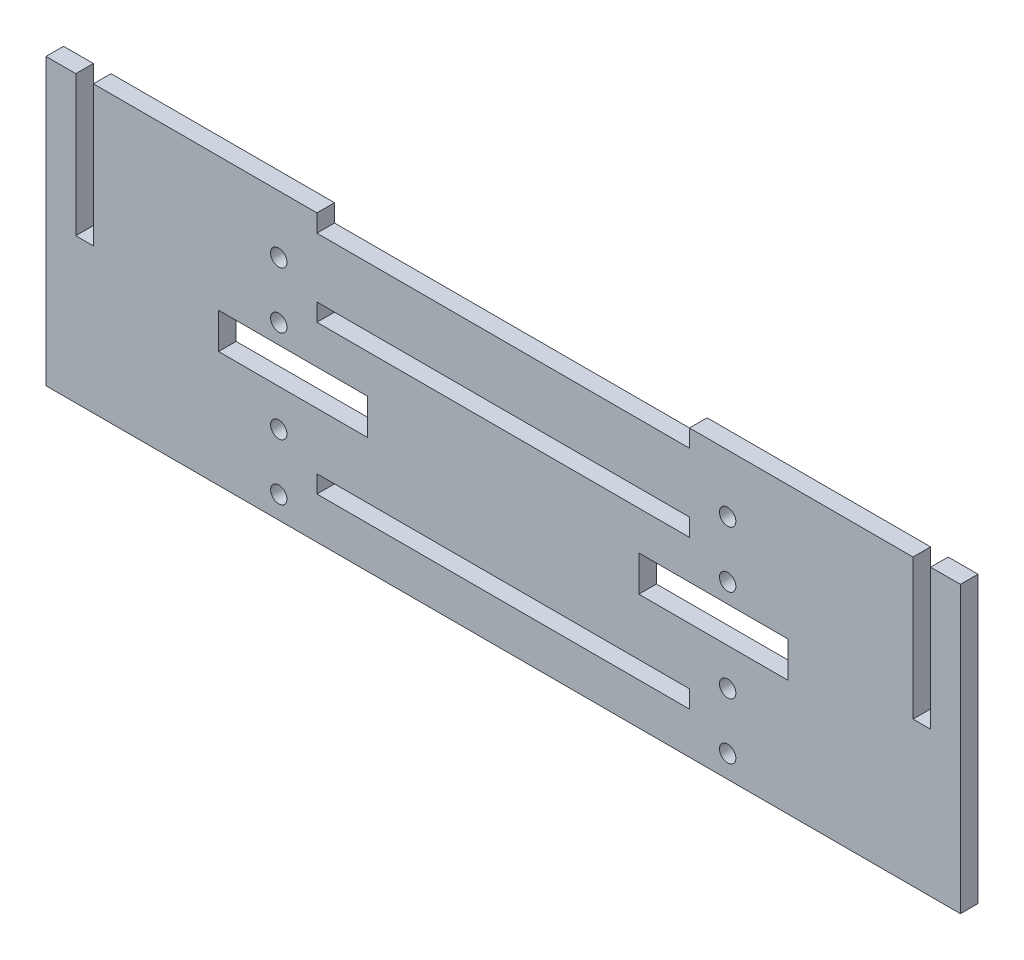
from build123d import *

# Parameters (mm, degrees)
SKETCH1_W           = 114.3
SKETCH1_H           = 2.9972
BOSS_EXTRUDE1_DEPTH = 2.9972
SKETCH2_R           = 1.397
CUT_EXTRUDE1_DEPTH  = 3.9972
SKETCH3_W           = 25.4
SKETCH3_H           = 2.9972
BOSS_EXTRUDE2_DEPTH = 2.9972
SKETCH4_W           = 155.8544
SKETCH4_H           = 0.762
BOSS_EXTRUDE3_DEPTH = 2.9972
SKETCH5_R           = 1.397
CUT_EXTRUDE2_DEPTH  = 3.9972
SKETCH7_R           = 1.397
CUT_EXTRUDE3_DEPTH  = 3.9972
SKETCH6_W           = 25.4
SKETCH6_H           = 6.096
CUT_EXTRUDE4_DEPTH  = 3.9972


with BuildPart() as part:
    # Sketch1 → Boss-Extrude1 (new body)
    with BuildSketch(Plane.XY):
        Polygon((139.7, 23.9268), (139.7, 0), (147.7772, 0), (147.7772, 47.8536), (142.6972, 47.8536), (142.6972, 23.9268), align=None)
        Polygon((0, 23.9268), (0, 0), (139.7, 0), (139.7, 23.9268), (139.7, 47.8536), (127, 47.8536), (127, 44.8564), (12.7, 44.8564), (12.7, 47.8536), (0, 47.8536), align=None)
        with Locations((69.85, 7.8486)):
            Rectangle(SKETCH1_W, SKETCH1_H, mode=Mode.SUBTRACT)
        with Locations((69.85, 33.1978)):
            Rectangle(SKETCH1_W, SKETCH1_H, mode=Mode.SUBTRACT)
        Polygon((-8.0772, 0), (0, 0), (0, 23.9268), (-2.9972, 23.9268), (-2.9972, 47.8536), (-8.0772, 47.8536), align=None)
    extrude(amount=BOSS_EXTRUDE1_DEPTH)

    # Sketch2 → Cut-Extrude1 (cut, through all)
    with BuildSketch(Plane(origin=(0, 0, 0), x_dir=(-1, 0, 0), z_dir=(0, 0, -1))):
        with Locations((-108.1024, 12.6492)):
            Circle(SKETCH2_R)
        with Locations((-31.5976, 12.6492)):
            Circle(SKETCH2_R)
        with Locations((-108.1024, 37.9984)):
            Circle(SKETCH2_R)
        with Locations((-31.5976, 37.9984)):
            Circle(SKETCH2_R)
    extrude(amount=-CUT_EXTRUDE1_DEPTH, mode=Mode.SUBTRACT)

    # Sketch3 → Boss-Extrude2 (add)
    with BuildSketch(Plane(origin=(0, 0, 0), x_dir=(-1, 0, 0), z_dir=(0, 0, -1))):
        with Locations((-114.3, 46.355)):
            Rectangle(SKETCH3_W, SKETCH3_H)
        with Locations((-114.3, 33.1978)):
            Rectangle(SKETCH3_W, SKETCH3_H)
        with Locations((-114.3, 7.8486)):
            Rectangle(SKETCH3_W, SKETCH3_H)
        with Locations((-25.4, 7.8486)):
            Rectangle(SKETCH3_W, SKETCH3_H)
        with Locations((-25.4, 33.1978)):
            Rectangle(SKETCH3_W, SKETCH3_H)
        with Locations((-25.4, 46.355)):
            Rectangle(SKETCH3_W, SKETCH3_H)
    extrude(amount=-BOSS_EXTRUDE2_DEPTH)

    # Sketch4 → Boss-Extrude3 (add)
    with BuildSketch(Plane(origin=(0, 0, 0), x_dir=(-1, 0, 0), z_dir=(0, 0, -1))):
        with Locations((-69.85, -0.381)):
            Rectangle(SKETCH4_W, SKETCH4_H)
    extrude(amount=-BOSS_EXTRUDE3_DEPTH)

    # Sketch5 → Cut-Extrude2 (cut, through all)
    with BuildSketch(Plane.XY.offset(2.9972)):
        with Locations((31.5976, 28.3972)):
            Circle(SKETCH5_R)
        with Locations((108.1024, 28.3972)):
            Circle(SKETCH5_R)
    extrude(amount=-CUT_EXTRUDE2_DEPTH, mode=Mode.SUBTRACT)

    # Sketch7 → Cut-Extrude3 (cut, through all)
    with BuildSketch(Plane(origin=(0, 0, 0), x_dir=(-1, 0, 0), z_dir=(0, 0, -1))):
        with Locations((-108.1024, 3.048)):
            Circle(SKETCH7_R)
        with Locations((-31.5976, 3.048)):
            Circle(SKETCH7_R)
    extrude(amount=-CUT_EXTRUDE3_DEPTH, mode=Mode.SUBTRACT)

    # Sketch6 → Cut-Extrude4 (cut, through all)
    with BuildSketch(Plane.XY.offset(2.9972)):
        with Locations((34.036, 22.0472)):
            Rectangle(SKETCH6_W, SKETCH6_H)
        with Locations((105.664, 22.0472)):
            Rectangle(SKETCH6_W, SKETCH6_H)
    extrude(amount=-CUT_EXTRUDE4_DEPTH, mode=Mode.SUBTRACT)


solid = part.part
